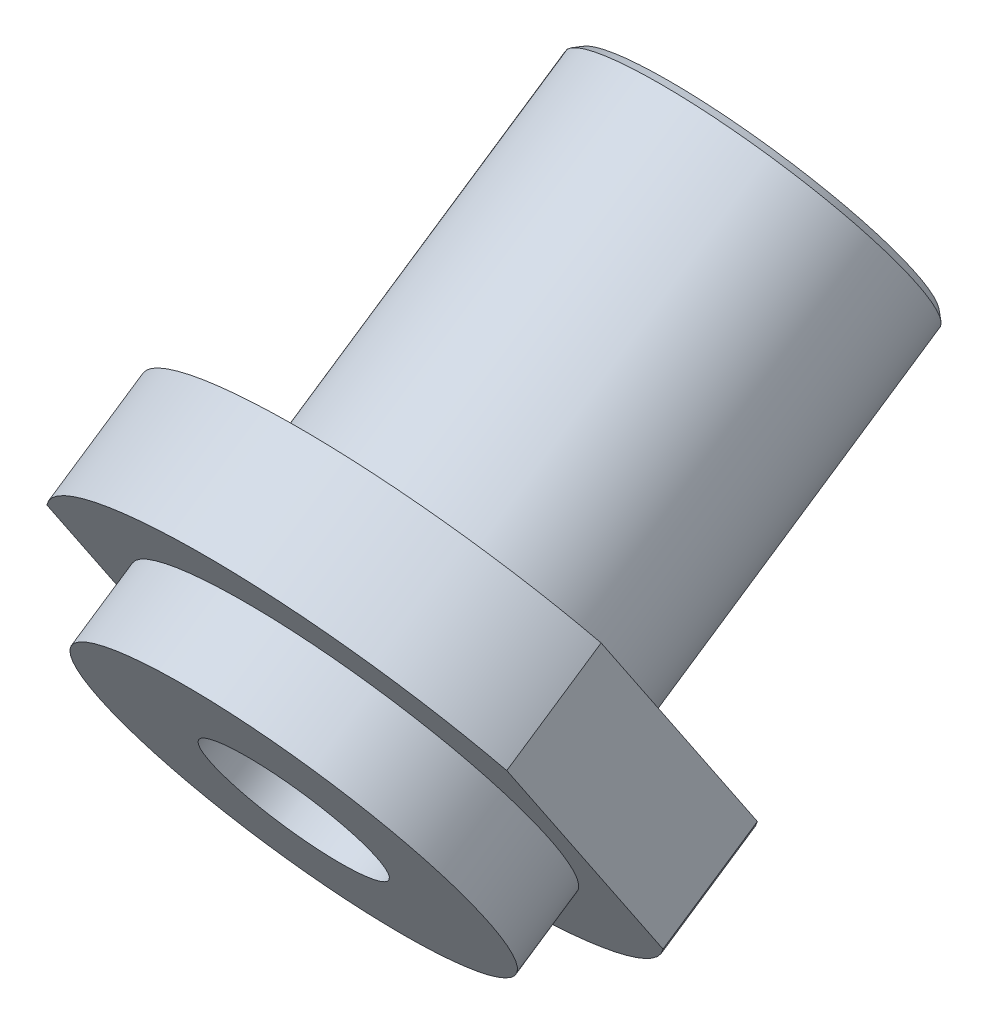
from build123d import *

# Parameters (mm, degrees)
SKETCH2_R              = 6.6929
BOSS_EXTRUDE1_DEPTH    = 15.113
SKETCH3_R              = 6.6929
BOSS_EXTRUDE2_DEPTH    = 4.62026
SKETCH4_R              = 7.9502
BOSS_EXTRUDE3_DEPTH    = 2.99974
M8X1_25_TAPPED_HOLE1_D = 6.8
CHAMFER2_SIZE          = 0.254


with BuildPart() as part:
    # Sketch2 → Boss-Extrude1 (new body)
    with BuildSketch(Plane(origin=(0, -87.315503791, 130.072474606), x_dir=(1, 0, 0), z_dir=(0, -0.557351153, 0.830276877))):
        with Locations((0, 484.511457201)):
            Circle(SKETCH2_R)
    extrude(amount=-BOSS_EXTRUDE1_DEPTH)

    # Sketch3 → Boss-Extrude2 (add)
    with BuildSketch(Plane(origin=(0, -87.315503791, 130.072474606), x_dir=(1, 0, 0), z_dir=(0, -0.557351153, 0.830276877))):
        with BuildLine():
            Line((-9.34974, 478.812023199), (-9.34974, 490.210891202))
            ThreePointArc((-9.34974, 490.210891202), (0, 495.461397201), (9.34974, 490.210891202))
            Line((9.34974, 490.210891202), (9.34974, 478.812023199))
            ThreePointArc((9.34974, 478.812023199), (0, 473.561517201), (-9.34974, 478.812023199))
        make_face()
        with Locations((0, 484.511457201)):
            Circle(SKETCH3_R, mode=Mode.SUBTRACT)
        with Locations((0, 484.511457201)):
            Circle(SKETCH3_R)
    extrude(amount=BOSS_EXTRUDE2_DEPTH)

    # Sketch4 → Boss-Extrude3 (add)
    with BuildSketch(Plane(origin=(0, -89.890611031, 133.908569648), x_dir=(1, 0, 0), z_dir=(0, -0.557351153, 0.830276877))):
        with Locations((0, 484.511457201)):
            Circle(SKETCH4_R)
    extrude(amount=BOSS_EXTRUDE3_DEPTH)

    # M8x1.25 Tapped Hole1 (through all)
    with Locations(Plane(origin=(0, -91.56251958, 136.399184405), x_dir=(1, 0, 0), z_dir=(0, -0.557351153, 0.830276877))):
        with Locations((0, 484.511457201)):
            Hole(M8X1_25_TAPPED_HOLE1_D / 2)

    # Chamfer2
    chamfer2_edges = [part.edges().sort_by_distance(p)[0] for p in [
        (-6.6929, 323.386403518, 387.567519724),
    ]]
    chamfer(chamfer2_edges, length=CHAMFER2_SIZE)


solid = part.part
